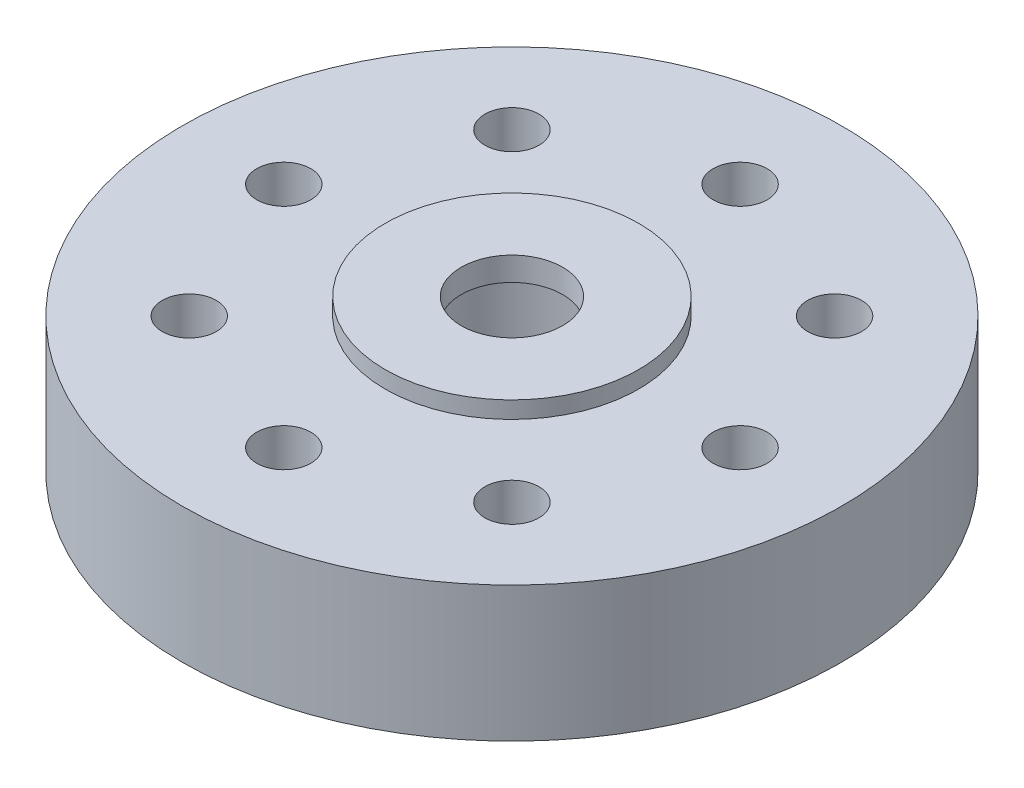
from build123d import *

# Parameters (mm, degrees)
CROQUIS1_R              = 9.75
CROQUIS1_R_2            = 0.8
CROQUIS1_R_3            = 1.5
SALIENTE_EXTRUIR1_DEPTH = 2
CROQUIS1_3_R            = 3.75
CROQUIS1_3_R_2          = 1.5
SALIENTE_EXTRUIR2_DEPTH = 2.5
CROQUIS2_R              = 4.4
CORTAR_EXTRUIR3_DEPTH   = 3.8
CROQUIS2_6_R            = 4.4
CROQUIS2_6_R_2          = 3.75
SALIENTE_EXTRUIR3_DEPTH = 0.5
CROQUIS2_9_R            = 2.5
CORTAR_EXTRUIR4_DEPTH   = 3.8


with BuildPart() as part:
    # Croquis1 → Saliente-Extruir1 (new, symmetric)
    with BuildSketch(Plane(origin=(0, 0, 0), x_dir=(1, 0, 0), z_dir=(0, 1, 0))):
        Circle(CROQUIS1_R)
        with Locations((-4.772970773, -4.772970773)):
            Circle(CROQUIS1_R_2, mode=Mode.SUBTRACT)
        with Locations((0, -6.75)):
            Circle(CROQUIS1_R_2, mode=Mode.SUBTRACT)
        with Locations((4.772970773, -4.772970773)):
            Circle(CROQUIS1_R_2, mode=Mode.SUBTRACT)
        with Locations((-6.75, 0)):
            Circle(CROQUIS1_R_2, mode=Mode.SUBTRACT)
        with Locations((-4.772970773, 4.772970773)):
            Circle(CROQUIS1_R_2, mode=Mode.SUBTRACT)
        with Locations((4.772970773, 4.772970773)):
            Circle(CROQUIS1_R_2, mode=Mode.SUBTRACT)
        with Locations((6.75, 0)):
            Circle(CROQUIS1_R_2, mode=Mode.SUBTRACT)
        with Locations((0, 6.75)):
            Circle(CROQUIS1_R_2, mode=Mode.SUBTRACT)
        Circle(CROQUIS1_R_3, mode=Mode.SUBTRACT)
    extrude(amount=SALIENTE_EXTRUIR1_DEPTH, both=True)

    # Croquis1_3 → Saliente-Extruir2 (add, symmetric)
    with BuildSketch(Plane(origin=(0, 0, 0), x_dir=(1, 0, 0), z_dir=(0, 1, 0))):
        Circle(CROQUIS1_3_R)
        Circle(CROQUIS1_3_R_2, mode=Mode.SUBTRACT)
    extrude(amount=SALIENTE_EXTRUIR2_DEPTH, both=True)

    # Croquis2 → Cortar-Extruir3 (cut)
    with BuildSketch(Plane.XZ.offset(2)):
        with BuildLine():
            ThreePointArc((8.493703704, -0.979539378), (4.75, 0), (8.493703704, 0.979539378))
            ThreePointArc((8.493703704, 0.979539378), (7.899170003, 3.271943347), (6.698594423, 5.313316549))
            ThreePointArc((6.698594423, 5.313316549), (6.754289437, 5.045691051), (6.772970773, 4.772970773))
            ThreePointArc((6.772970773, 4.772970773), (3.179124552, 3.564809267), (5.313316549, 6.698594423))
            ThreePointArc((5.313316549, 6.698594423), (3.271943347, 7.899170003), (0.979539378, 8.493703704))
            ThreePointArc((0.979539378, 8.493703704), (1.72613423, 7.76017851), (2, 6.75))
            ThreePointArc((2, 6.75), (-1.01017851, 5.02386577), (-0.979539378, 8.493703704))
            ThreePointArc((-0.979539378, 8.493703704), (-3.271943347, 7.899170003), (-5.313316549, 6.698594423))
            ThreePointArc((-5.313316549, 6.698594423), (-3.564809267, 6.366816994), (-2.772970773, 4.772970773))
            ThreePointArc((-2.772970773, 4.772970773), (-5.045691051, 2.791652109), (-6.698594423, 5.313316549))
            ThreePointArc((-6.698594423, 5.313316549), (-7.899170003, 3.271943347), (-8.493703704, 0.979539378))
            ThreePointArc((-8.493703704, 0.979539378), (-6.243742856, 1.934865293), (-4.75, 0))
            ThreePointArc((-4.75, 0), (-6.243742856, -1.934865293), (-8.493703704, -0.979539378))
            ThreePointArc((-8.493703704, -0.979539378), (-7.899170003, -3.271943347), (-6.698594423, -5.313316549))
            ThreePointArc((-6.698594423, -5.313316549), (-5.045691051, -2.791652109), (-2.772970773, -4.772970773))
            ThreePointArc((-2.772970773, -4.772970773), (-3.564809267, -6.366816994), (-5.313316549, -6.698594423))
            ThreePointArc((-5.313316549, -6.698594423), (-3.271943347, -7.899170003), (-0.979539378, -8.493703704))
            ThreePointArc((-0.979539378, -8.493703704), (-1.01017851, -5.02386577), (2, -6.75))
            ThreePointArc((2, -6.75), (1.72613423, -7.76017851), (0.979539378, -8.493703704))
            ThreePointArc((0.979539378, -8.493703704), (3.271943347, -7.899170003), (5.313316549, -6.698594423))
            ThreePointArc((5.313316549, -6.698594423), (3.179124552, -3.564809267), (6.772970773, -4.772970773))
            ThreePointArc((6.772970773, -4.772970773), (6.754289437, -5.045691051), (6.698594423, -5.313316549))
            ThreePointArc((6.698594423, -5.313316549), (7.899170003, -3.271943347), (8.493703704, -0.979539378))
        make_face()
        Circle(CROQUIS2_R, mode=Mode.SUBTRACT)
    extrude(amount=-CORTAR_EXTRUIR3_DEPTH, mode=Mode.SUBTRACT)

    # Croquis2_6 → Saliente-Extruir3 (add)
    with BuildSketch(Plane.XZ.offset(2)):
        Circle(CROQUIS2_6_R)
        Circle(CROQUIS2_6_R_2, mode=Mode.SUBTRACT)
    extrude(amount=SALIENTE_EXTRUIR3_DEPTH)

    # Croquis2_9 → Cortar-Extruir4 (cut, symmetric)
    with BuildSketch(Plane.XZ.offset(2)):
        Circle(CROQUIS2_9_R)
    extrude(amount=CORTAR_EXTRUIR4_DEPTH, both=True, mode=Mode.SUBTRACT)


solid = part.part
